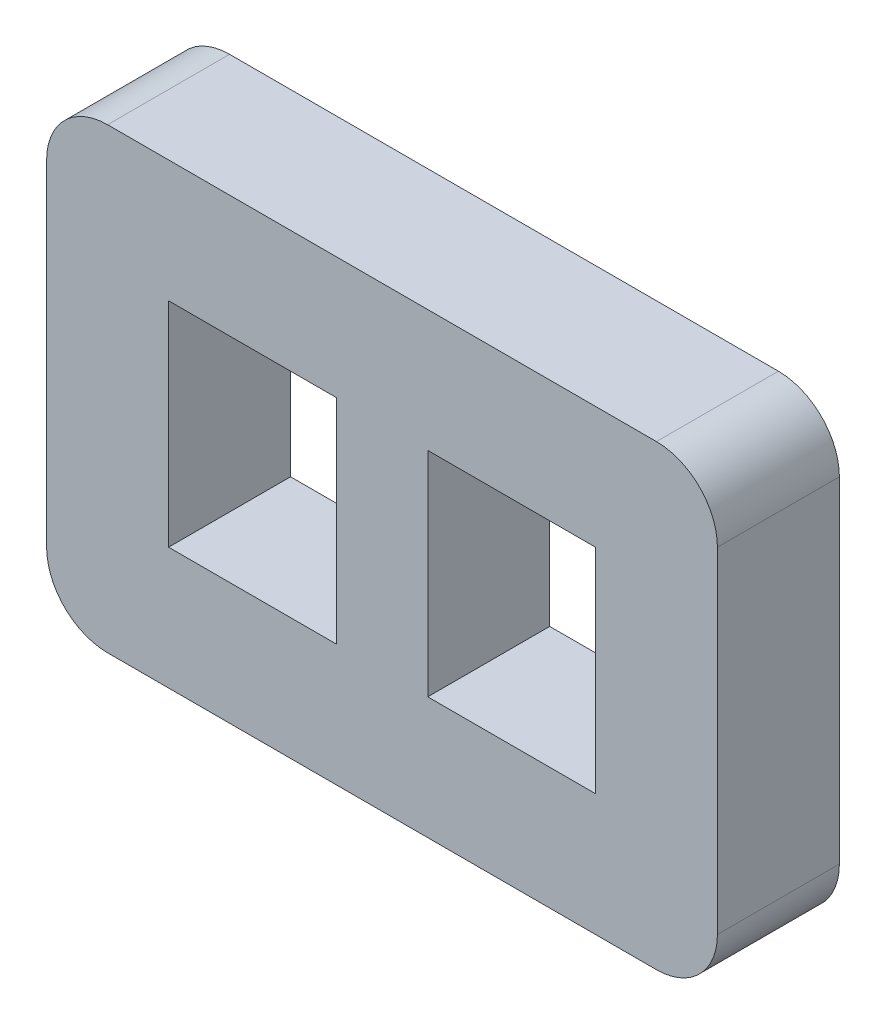
from build123d import *

# Parameters (mm, degrees)
SKETCH1_W           = 2.75
SKETCH1_H           = 3.5
BOSS_EXTRUDE1_DEPTH = 2


with BuildPart() as part:
    # Sketch1 → Boss-Extrude1 (new body)
    with BuildSketch(Plane.XY):
        with BuildLine():
            Line((4.5, 21.5), (-4.5, 21.5))
            ThreePointArc((-4.5, 21.5), (-5.207106781, 21.207106781), (-5.5, 20.5))
            Line((-5.5, 20.5), (-5.5, 15))
            ThreePointArc((-5.5, 15), (-5.207106781, 14.292893219), (-4.5, 14))
            Line((-4.5, 14), (4.5, 14))
            ThreePointArc((4.5, 14), (5.207106781, 14.292893219), (5.5, 15))
            Line((5.5, 15), (5.5, 20.5))
            ThreePointArc((5.5, 20.5), (5.207106781, 21.207106781), (4.5, 21.5))
        make_face()
        with Locations((2.125, 17.75)):
            Rectangle(SKETCH1_W, SKETCH1_H, mode=Mode.SUBTRACT)
        with Locations((-2.125, 17.75)):
            Rectangle(SKETCH1_W, SKETCH1_H, mode=Mode.SUBTRACT)
    extrude(amount=BOSS_EXTRUDE1_DEPTH)


solid = part.part
